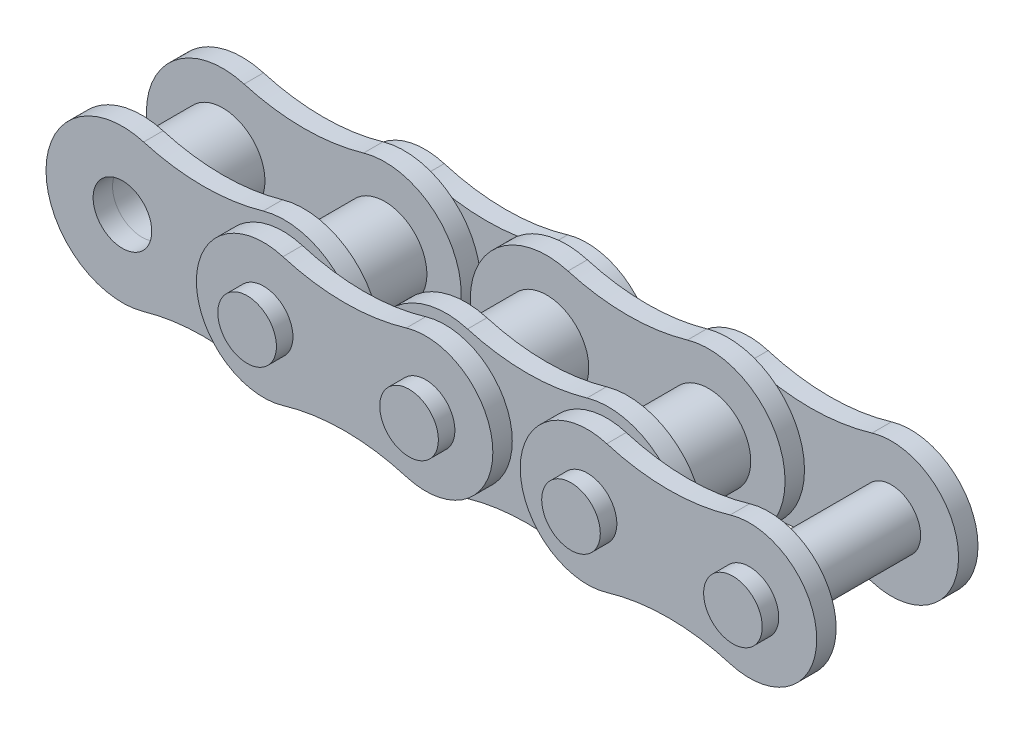
from build123d import *

# Parameters (mm, degrees)
SKETCH4_R                  = 1.651
SKETCH4_R_2                = 1.17475
BOSS_EXTRUDE1_DEPTH        = 1.5875
BOSS_EXTRUDE1_2_DEPTH      = 1.5875
SKETCH5_R                  = 1.14935
BOSS_EXTRUDE2_DEPTH        = 0.762
LPATTERN1_COUNT            = 2
LPATTERN1_PITCH            = 6.35
SKETCH7_R                  = 1.14935
BOSS_EXTRUDE3_DEPTH        = 0.762
SKETCH8_R                  = 1.14935
BOSS_EXTRUDE4_DEPTH        = 3.81
BOSS_EXTRUDE4_DEPTH_BACK   = 3.81
BOSS_EXTRUDE4_2_DEPTH      = 3.81
BOSS_EXTRUDE4_2_DEPTH_BACK = 3.81
LPATTERN2_COUNT            = 2
LPATTERN2_PITCH            = 12.7


with BuildPart() as part:
    # Sketch4 → Boss-Extrude1 (new body, symmetric)
    with BuildSketch(Plane.XY):
        with Locations((-3.175, 0)):
            Circle(SKETCH4_R)
        with Locations((-3.175, 0)):
            Circle(SKETCH4_R_2, mode=Mode.SUBTRACT)
    extrude(amount=BOSS_EXTRUDE1_DEPTH, both=True)


with BuildPart() as body_2:
    # Sketch4 → Boss-Extrude1 2 (new body, symmetric)
    with BuildSketch(Plane.XY):
        with Locations((3.175, 0)):
            Circle(SKETCH4_R)
        with Locations((3.175, 0)):
            Circle(SKETCH4_R_2, mode=Mode.SUBTRACT)
    extrude(amount=BOSS_EXTRUDE1_2_DEPTH, both=True)


with BuildPart() as body_3:
    # Sketch5 → Boss-Extrude2 (new body)
    with BuildSketch(Plane.XY.offset(1.5875)):
        with BuildLine():
            ThreePointArc((-2.342877482, 2.879371452), (-6.1722, 0), (-2.342877482, -2.879371452))
            ThreePointArc((-2.342877482, -2.879371452), (0, -2.54762), (2.342877482, -2.879371452))
            ThreePointArc((2.342877482, -2.879371452), (6.1722, 0), (2.342877482, 2.879371452))
            ThreePointArc((2.342877482, 2.879371452), (0, 2.54762), (-2.342877482, 2.879371452))
        make_face()
        with Locations((-3.175, 0)):
            Circle(SKETCH5_R, mode=Mode.SUBTRACT)
        with Locations((3.175, 0)):
            Circle(SKETCH5_R, mode=Mode.SUBTRACT)
    extrude(amount=BOSS_EXTRUDE2_DEPTH)


with BuildPart() as lpattern1_1:
    # LPattern1: pattern copy
    add(body_2.part.moved(Location(Vector(1, 0, 0) * (1 * LPATTERN1_PITCH))))


with BuildPart() as body_5:
    # Sketch7 → Boss-Extrude3 (new body)
    with BuildSketch(Plane.XY.offset(-2.4003)):
        with BuildLine():
            ThreePointArc((3.931045679, 2.526853989), (0.537464, 0), (3.931045679, -2.526853989))
            ThreePointArc((3.931045679, -2.526853989), (6.35, -2.17272892), (8.768954321, -2.526853989))
            ThreePointArc((8.768954321, -2.526853989), (12.162536, 0), (8.768954321, 2.526853989))
            ThreePointArc((8.768954321, 2.526853989), (6.35, 2.17272892), (3.931045679, 2.526853989))
        make_face()
        with Locations((3.175, 0)):
            Circle(SKETCH7_R, mode=Mode.SUBTRACT)
        with Locations((9.525, 0)):
            Circle(SKETCH7_R, mode=Mode.SUBTRACT)
    extrude(amount=-BOSS_EXTRUDE3_DEPTH)


with BuildPart() as body_6:
    # Mirror1: mirrored copy
    add(body_3.part.mirror(Plane.XY))


with BuildPart() as body_7:
    # Mirror1 2: mirrored copy
    add(body_5.part.mirror(Plane.XY))


with BuildPart() as body_8:
    # Sketch8 → Boss-Extrude4 (new body, two sides)
    with BuildSketch(Plane.XY) as boss_extrude4_sk:
        with Locations((3.175, 0)):
            Circle(SKETCH8_R)
    extrude(amount=BOSS_EXTRUDE4_DEPTH)
    extrude(boss_extrude4_sk.sketch, amount=-BOSS_EXTRUDE4_DEPTH_BACK)


with BuildPart() as body_9:
    # Sketch8 → Boss-Extrude4 2 (new body, two sides)
    with BuildSketch(Plane.XY) as boss_extrude4_2_sk:
        with Locations((9.525, 0)):
            Circle(SKETCH8_R)
    extrude(amount=BOSS_EXTRUDE4_2_DEPTH)
    extrude(boss_extrude4_2_sk.sketch, amount=-BOSS_EXTRUDE4_2_DEPTH_BACK)


with BuildPart() as lpattern2_1:
    # LPattern2: pattern copy
    add(body_9.part.moved(Location(Vector(1, 0, 0) * (1 * LPATTERN2_PITCH))))


with BuildPart() as lpattern2_2:
    # LPattern2: pattern copy
    add(body_8.part.moved(Location(Vector(1, 0, 0) * (1 * LPATTERN2_PITCH))))


with BuildPart() as lpattern2_3:
    # LPattern2: pattern copy
    add(body_7.part.moved(Location(Vector(1, 0, 0) * (1 * LPATTERN2_PITCH))))


with BuildPart() as lpattern2_4:
    # LPattern2: pattern copy
    add(body_6.part.moved(Location(Vector(1, 0, 0) * (1 * LPATTERN2_PITCH))))


with BuildPart() as lpattern2_5:
    # LPattern2: pattern copy
    add(body_5.part.moved(Location(Vector(1, 0, 0) * (1 * LPATTERN2_PITCH))))


with BuildPart() as lpattern2_6:
    # LPattern2: pattern copy
    add(lpattern1_1.part.moved(Location(Vector(1, 0, 0) * (1 * LPATTERN2_PITCH))))


with BuildPart() as lpattern2_7:
    # LPattern2: pattern copy
    add(body_3.part.moved(Location(Vector(1, 0, 0) * (1 * LPATTERN2_PITCH))))


with BuildPart() as lpattern2_8:
    # LPattern2: pattern copy
    add(body_2.part.moved(Location(Vector(1, 0, 0) * (1 * LPATTERN2_PITCH))))


with BuildPart() as lpattern2_9:
    # LPattern2: pattern copy
    add(part.part.moved(Location(Vector(1, 0, 0) * (1 * LPATTERN2_PITCH))))


with BuildPart() as body_2_1:
    add(body_2.part)

    # Combine1: union body 3, LPattern1_1, body 5, body 6, body 7, body 8, body 9, LPattern2_1, LPattern2_2, LPattern2_3, LPattern2_4, LPattern2_5, LPattern2_7, LPattern2_8, LPattern2_9, part
    add(body_3.part)
    add(lpattern1_1.part)
    add(body_5.part)
    add(body_6.part)
    add(body_7.part)
    add(body_8.part)
    add(body_9.part)
    add(lpattern2_1.part)
    add(lpattern2_2.part)
    add(lpattern2_3.part)
    add(lpattern2_4.part)
    add(lpattern2_5.part)
    add(lpattern2_7.part)
    add(lpattern2_8.part)
    add(lpattern2_9.part)
    add(part.part)


solid = body_2_1.part
